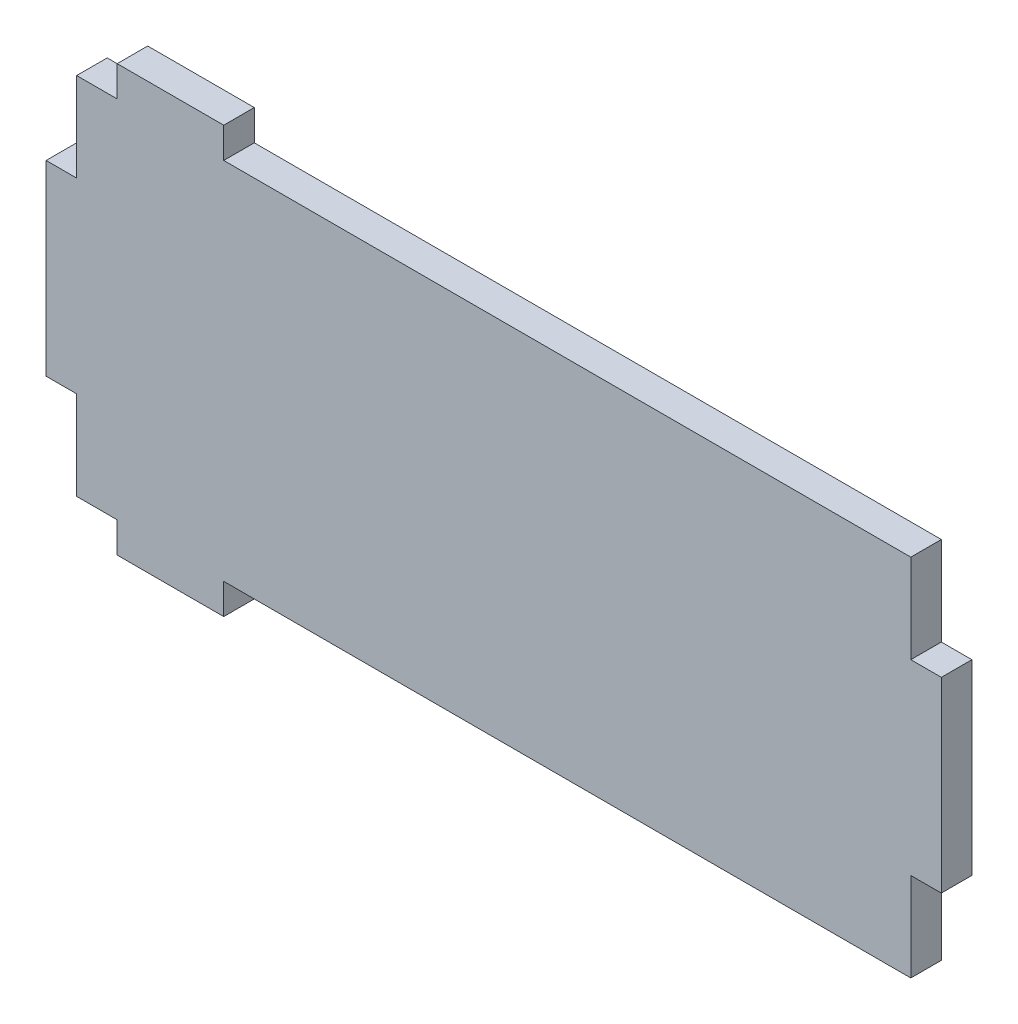
from build123d import *

# Parameters (mm, degrees)
SKETCH1_W           = 160.02
SKETCH1_H           = 65.151
BOSS_EXTRUDE1_DEPTH = 5.461
SKETCH2_W           = 5.461
SKETCH2_H           = 15.875
CUT_EXTRUDE1_DEPTH  = 6.461
SKETCH4_W           = 19.05
SKETCH4_H           = 5.461
BOSS_EXTRUDE3_DEPTH = 5.461


with BuildPart() as part:
    # Sketch1 → Boss-Extrude1 (new body)
    with BuildSketch(Plane.XY):
        Rectangle(SKETCH1_W, SKETCH1_H)
    extrude(amount=BOSS_EXTRUDE1_DEPTH)

    # Sketch2 → Cut-Extrude1 (cut, through all)
    with BuildSketch(Plane.XY.offset(5.461)):
        with Locations((-77.2795, 24.638)):
            Rectangle(SKETCH2_W, SKETCH2_H)
        with Locations((-77.2795, -24.638)):
            Rectangle(SKETCH2_W, SKETCH2_H)
        with Locations((77.2795, 24.638)):
            Rectangle(SKETCH2_W, SKETCH2_H)
        with Locations((77.2795, -24.638)):
            Rectangle(SKETCH2_W, SKETCH2_H)
    extrude(amount=-CUT_EXTRUDE1_DEPTH, mode=Mode.SUBTRACT)

    # Sketch4 → Boss-Extrude3 (add)
    with BuildSketch(Plane.XY.offset(5.461)):
        with Locations((-57.785, 35.306)):
            Rectangle(SKETCH4_W, SKETCH4_H)
        with Locations((-57.785, -35.306)):
            Rectangle(SKETCH4_W, SKETCH4_H)
    extrude(amount=-BOSS_EXTRUDE3_DEPTH)


solid = part.part
